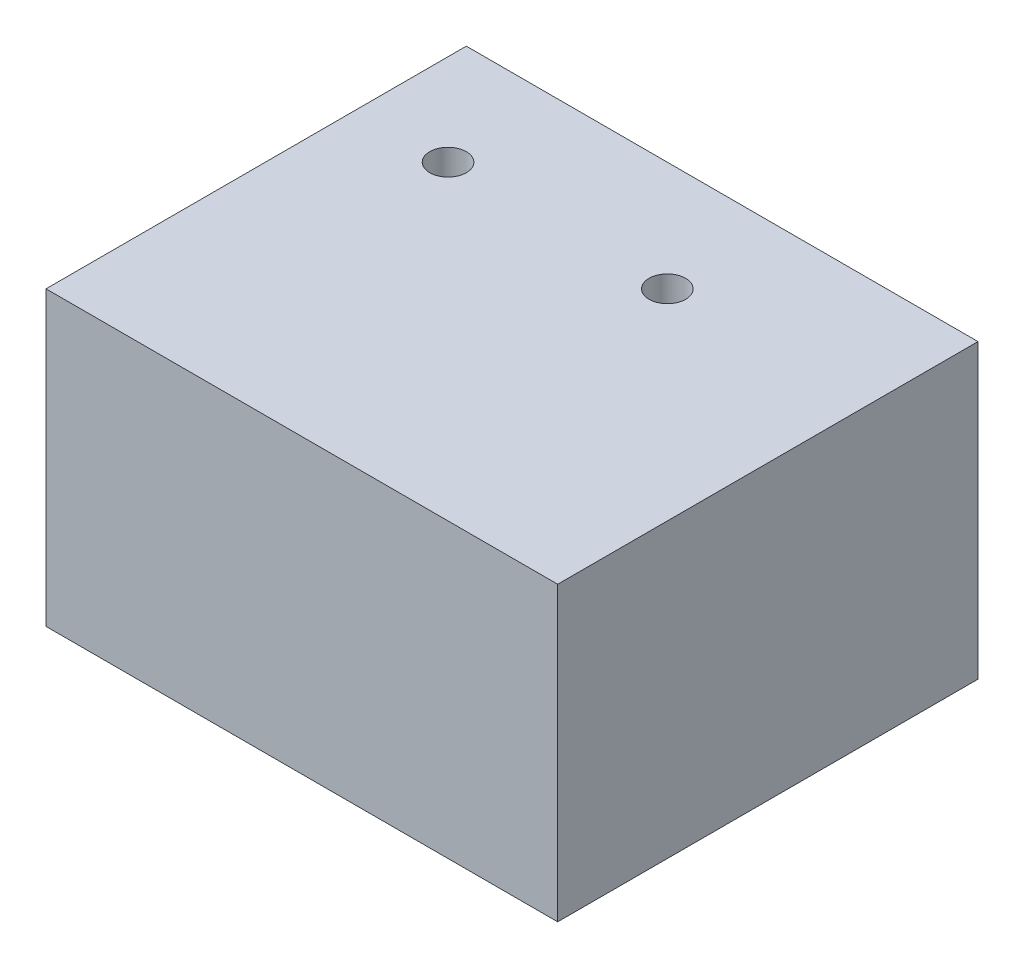
from build123d import *

# Parameters (mm, degrees)
SKETCH1_W                        = 140
SKETCH1_H                        = 115
BOSS_EXTRUDE1_DEPTH              = 80
SKETCH3_W                        = 126
SKETCH3_H                        = 66
CUT_EXTRUDE1_DEPTH               = 108
M10X1_0_TAPPED_HOLE1_D           = 9
M10X1_0_TAPPED_HOLE1_DEPTH       = 23
M10X1_0_TAPPED_HOLE1_CBORE_D     = 10
M10X1_0_TAPPED_HOLE1_CBORE_DEPTH = 20
M10X1_0_TAPPED_HOLE1_TIP         = 2.703872786
M10X1_0_TAPPED_HOLE2_D           = 9
M10X1_0_TAPPED_HOLE2_DEPTH       = 23
M10X1_0_TAPPED_HOLE2_CBORE_D     = 10
M10X1_0_TAPPED_HOLE2_CBORE_DEPTH = 20
M10X1_0_TAPPED_HOLE2_TIP         = 2.703872786


with BuildPart() as part:
    # Sketch1 → Boss-Extrude1 (new body)
    with BuildSketch(Plane(origin=(0, 0, 0), x_dir=(1, 0, 0), z_dir=(0, 1, 0))):
        with Locations((23.905213361, 33.54681393)):
            Rectangle(SKETCH1_W, SKETCH1_H)
    extrude(amount=BOSS_EXTRUDE1_DEPTH)

    # Sketch3 → Cut-Extrude1 (cut)
    with BuildSketch(Plane(origin=(0, 0, -91.04681393), x_dir=(-1, 0, 0), z_dir=(0, 0, -1))):
        with Locations((-23.905213361, 40)):
            Rectangle(SKETCH3_W, SKETCH3_H)
    extrude(amount=-CUT_EXTRUDE1_DEPTH, mode=Mode.SUBTRACT)

    # M10x1.0 Tapped Hole1
    with Locations(Plane(origin=(0, 80, 0), x_dir=(1, 0, 0), z_dir=(0, 1, 0))):
        with Locations((-21.094786639, 61.04681393), (38.905213361, 61.04681393)):
            CounterBoreHole(M10X1_0_TAPPED_HOLE1_D / 2, M10X1_0_TAPPED_HOLE1_CBORE_D / 2, M10X1_0_TAPPED_HOLE1_CBORE_DEPTH, depth=M10X1_0_TAPPED_HOLE1_DEPTH)
            with Locations((0, 0, -(M10X1_0_TAPPED_HOLE1_DEPTH + M10X1_0_TAPPED_HOLE1_TIP / 2))):  # 118° drill point
                Cone(0, M10X1_0_TAPPED_HOLE1_D / 2, M10X1_0_TAPPED_HOLE1_TIP, mode=Mode.SUBTRACT)

    # M10x1.0 Tapped Hole2
    with Locations(Plane.ZY.offset(46.094786639)):
        with Locations((-51.04681393, 15)):
            CounterBoreHole(M10X1_0_TAPPED_HOLE2_D / 2, M10X1_0_TAPPED_HOLE2_CBORE_D / 2, M10X1_0_TAPPED_HOLE2_CBORE_DEPTH, depth=M10X1_0_TAPPED_HOLE2_DEPTH)
            with Locations((0, 0, -(M10X1_0_TAPPED_HOLE2_DEPTH + M10X1_0_TAPPED_HOLE2_TIP / 2))):  # 118° drill point
                Cone(0, M10X1_0_TAPPED_HOLE2_D / 2, M10X1_0_TAPPED_HOLE2_TIP, mode=Mode.SUBTRACT)


solid = part.part
